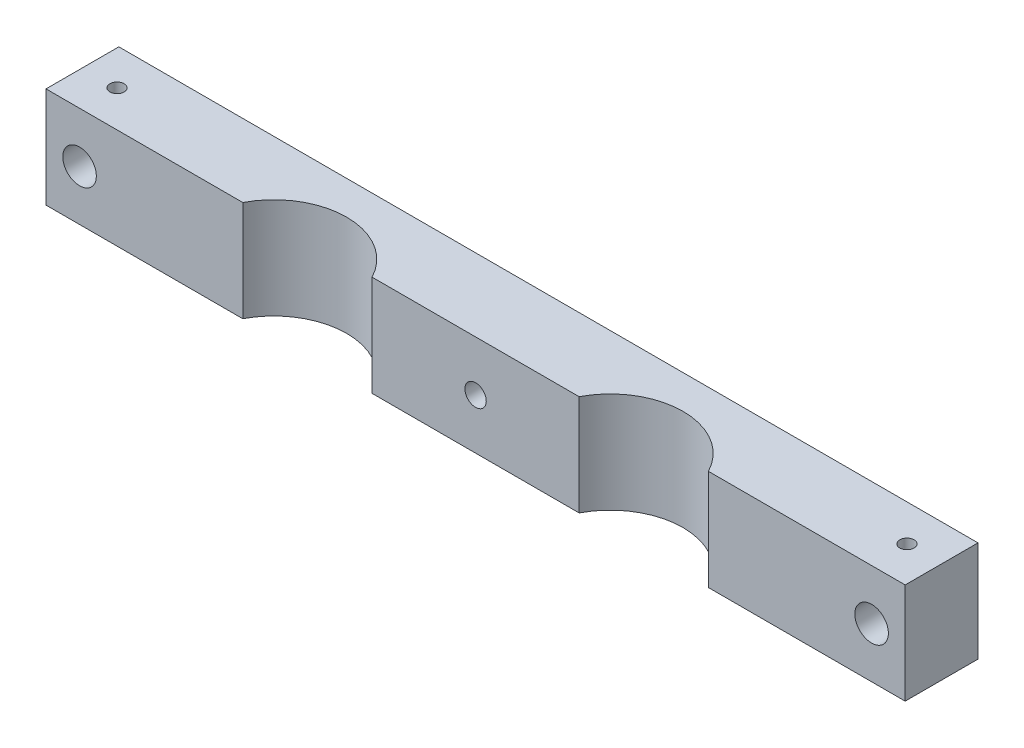
from build123d import *

# Parameters (mm, degrees)
BOSS_EXTRUDE1_DEPTH         = 19.05
F_1_4_0_25_DIAMETER_HOLE1_D = 6.35
F_6_32_TAPPED_HOLE1_REACH   = 86.612
F_6_32_TAPPED_HOLE1_BORE_R  = 1.35255
F_10_32_TAPPED_HOLE1_D      = 4.0386


with BuildPart() as part:
    # Sketch1 → Boss-Extrude1 (new body)
    with BuildSketch(Plane(origin=(0, 0, 0), x_dir=(1, 0, 0), z_dir=(0, 1, 0))):
        with BuildLine():
            Line((-19.59069957, 0), (19.59069957, 0))
            ThreePointArc((19.59069957, 0), (31.81985, 7.4295), (44.04900043, 0))
            Line((44.04900043, 0), (81.28, 0))
            Line((81.28, 0), (81.28, 13.7795))
            Line((81.28, 13.7795), (-81.28, 13.7795))
            Line((-81.28, 13.7795), (-81.28, 0))
            Line((-81.28, 0), (-44.04900043, 0))
            ThreePointArc((-44.04900043, 0), (-31.81985, 7.4295), (-19.59069957, 0))
        make_face()
    extrude(amount=BOSS_EXTRUDE1_DEPTH)

    # 1/4 (0.25) Diameter Hole1 (through all)
    with Locations(Plane.XY):
        with Locations((-74.93, 9.525)):
            f_1_4_0_25_diameter_hole1 = Hole(F_1_4_0_25_DIAMETER_HOLE1_D / 2)

    # #6-32 Tapped Hole1 bore → #6-32 Tapped Hole1 (cut, up to next)
    with BuildSketch(Plane(origin=(0, 19.05, 0), x_dir=(1, 0, 0), z_dir=(0, 1, 0)), mode=Mode.PRIVATE) as f_6_32_tapped_hole1_sk1:
        with Locations((-74.72934, 6.88975)):
            Circle(F_6_32_TAPPED_HOLE1_BORE_R)
    f_6_32_tapped_hole1_tool1 = extrude(f_6_32_tapped_hole1_sk1.sketch, amount=-F_6_32_TAPPED_HOLE1_REACH, mode=Mode.PRIVATE) & part.part
    f_6_32_tapped_hole1 = f_6_32_tapped_hole1_tool1.solids().sort_by_distance((-74.72934, 19.05, -6.88975))[0]
    add(f_6_32_tapped_hole1, mode=Mode.SUBTRACT)

    # Mirror2: 1/4 (0.25) Diameter Hole1, #6-32 Tapped Hole1 across plane
    add(f_1_4_0_25_diameter_hole1.mirror(Plane(origin=(0, 0, 0), x_dir=(0, 0, 1), z_dir=(1, 0, 0))), mode=Mode.SUBTRACT)
    add(f_6_32_tapped_hole1.mirror(Plane(origin=(0, 0, 0), x_dir=(0, 0, 1), z_dir=(1, 0, 0))), mode=Mode.SUBTRACT)

    # #10-32 Tapped Hole1 (through all)
    with Locations(Plane.XY):
        with Locations((0, 9.525)):
            Hole(F_10_32_TAPPED_HOLE1_D / 2)


solid = part.part
